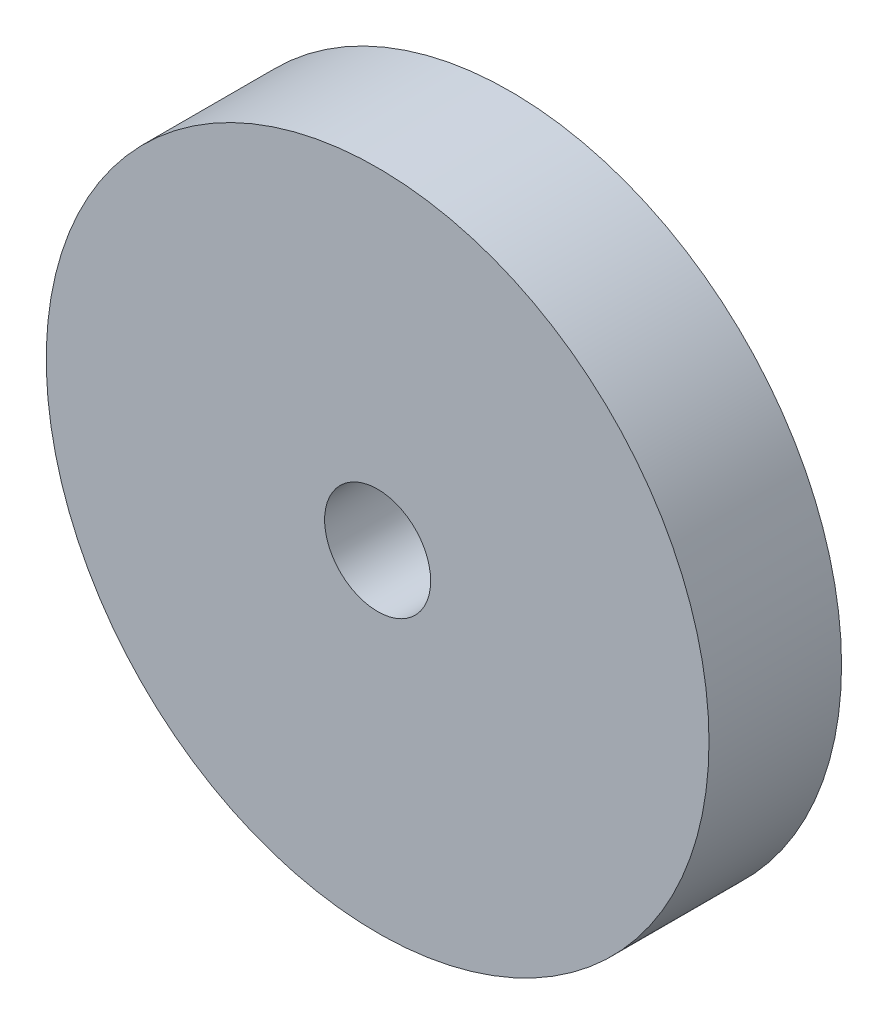
from build123d import *

# Parameters (mm, degrees)
SKETCH1_R            = 10
BOSS_EXTRUDE1_DEPTH  = 4
M3_CLEARANCE_HOLE1_D = 3.2


with BuildPart() as part:
    # Sketch1 → Boss-Extrude1 (new body)
    with BuildSketch(Plane.XY):
        with Locations((-98.463578367, -276.505149474)):
            Circle(SKETCH1_R)
    extrude(amount=BOSS_EXTRUDE1_DEPTH)

    # M3 Clearance Hole1 (through all)
    with Locations(Plane.XY.offset(4)):
        with Locations((-98.463578367, -276.505149474)):
            Hole(M3_CLEARANCE_HOLE1_D / 2)


solid = part.part
